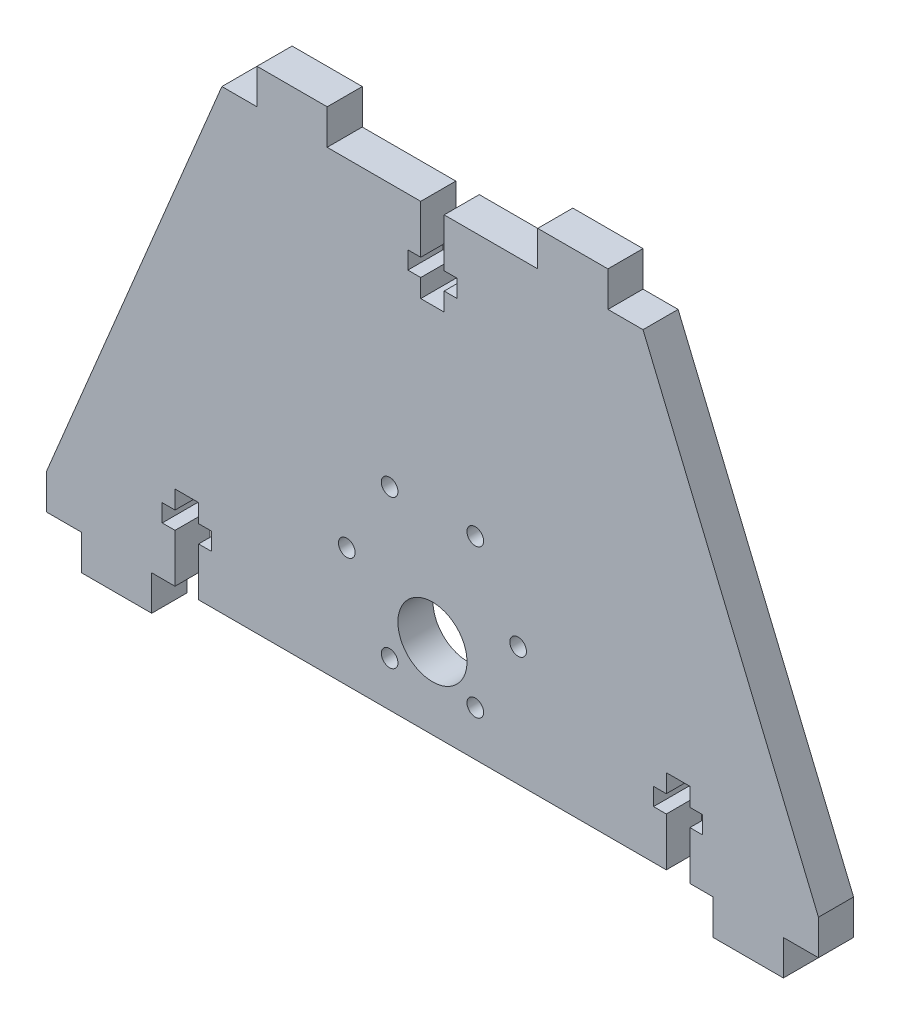
from build123d import *

# Parameters (mm, degrees)
SKETCH1_W           = 139.7
SKETCH1_H           = 82.55
BOSS_EXTRUDE1_DEPTH = 6.35
SKETCH2_W           = 12.7
SKETCH2_H           = 6.35
BOSS_EXTRUDE2_DEPTH = 6.35
CUT_EXTRUDE1_DEPTH  = 6.35
CUT_EXTRUDE8_DEPTH  = 6.35
CUT_EXTRUDE2_DEPTH  = 6.35
SKETCH5_R           = 6.254
SKETCH5_R_2         = 1.504
CUT_EXTRUDE9_DEPTH  = 6.35


with BuildPart() as part:
    # Sketch1 → Boss-Extrude1 (new body)
    with BuildSketch(Plane.XY):
        Rectangle(SKETCH1_W, SKETCH1_H)
    extrude(amount=BOSS_EXTRUDE1_DEPTH)

    # Sketch2 → Boss-Extrude2 (add)
    with BuildSketch(Plane(origin=(0, 0, 0), x_dir=(-1, 0, 0), z_dir=(0, 0, -1))):
        with Locations((-57.15, -44.45)):
            Rectangle(SKETCH2_W, SKETCH2_H)
        with Locations((-25.4, 44.45)):
            Rectangle(SKETCH2_W, SKETCH2_H)
    boss_extrude2 = extrude(amount=-BOSS_EXTRUDE2_DEPTH)

    # Sketch3 → Cut-Extrude1 (cut)
    with BuildSketch(Plane(origin=(0, 0, 0), x_dir=(-1, 0, 0), z_dir=(0, 0, -1))):
        Polygon((-46.5836, -41.275), (-46.5836, -32.512), (-48.895, -32.512), (-48.895, -29.337), (-46.5836, -29.337), (-46.5836, -26.035), (-42.3164, -26.035), (-42.3164, -29.337), (-40.005, -29.337), (-40.005, -32.512), (-42.3164, -32.512), (-42.3164, -41.275), align=None)
    cut_extrude1 = extrude(amount=-CUT_EXTRUDE1_DEPTH, mode=Mode.SUBTRACT)

    # Sketch7 → Cut-Extrude8 (cut)
    with BuildSketch(Plane(origin=(0, 0, 0), x_dir=(-1, 0, 0), z_dir=(0, 0, -1))):
        Polygon((-38.1, 41.275), (-69.85, -34.925), (-69.85, 41.275), align=None)
    cut_extrude8 = extrude(amount=-CUT_EXTRUDE8_DEPTH, mode=Mode.SUBTRACT)

    # Mirror2: Boss-Extrude2, Cut-Extrude8 across plane
    add(boss_extrude2.mirror(Plane(origin=(0, 0, 0), x_dir=(0, 0, 1), z_dir=(1, 0, 0))))
    add(cut_extrude8.mirror(Plane(origin=(0, 0, 0), x_dir=(0, 0, 1), z_dir=(1, 0, 0))), mode=Mode.SUBTRACT)

    # Mirror4: Cut-Extrude1 across plane
    add(cut_extrude1.mirror(Plane(origin=(0, 0, 0), x_dir=(0, 0, 1), z_dir=(1, 0, 0))), mode=Mode.SUBTRACT)

    # Sketch4 → Cut-Extrude2 (cut)
    with BuildSketch(Plane(origin=(0, 0, 0), x_dir=(-1, 0, 0), z_dir=(0, 0, -1))):
        Polygon((2.1209, 41.275), (-2.1209, 41.275), (-2.1209, 32.512), (-4.445, 32.512), (-4.445, 29.337), (-2.1209, 29.337), (-2.1209, 26.035), (2.1209, 26.035), (2.1209, 29.337), (4.445, 29.337), (4.445, 32.512), (2.1209, 32.512), align=None)
    extrude(amount=-CUT_EXTRUDE2_DEPTH, mode=Mode.SUBTRACT)

    # Sketch5 → Cut-Extrude9 (cut)
    with BuildSketch(Plane(origin=(0, 0, 0), x_dir=(-1, 0, 0), z_dir=(0, 0, -1))):
        with Locations((0, -26.7)):
            Circle(SKETCH5_R)
        with Locations((-15.5, -19.7)):
            Circle(SKETCH5_R_2)
        with Locations((-7.75, -6.276606241)):
            Circle(SKETCH5_R_2)
        with Locations((7.75, -6.276606241)):
            Circle(SKETCH5_R_2)
        with Locations((15.5, -19.7)):
            Circle(SKETCH5_R_2)
        with Locations((7.75, -33.123393759)):
            Circle(SKETCH5_R_2)
        with Locations((-7.75, -33.123393759)):
            Circle(SKETCH5_R_2)
    extrude(amount=-CUT_EXTRUDE9_DEPTH, mode=Mode.SUBTRACT)


solid = part.part
